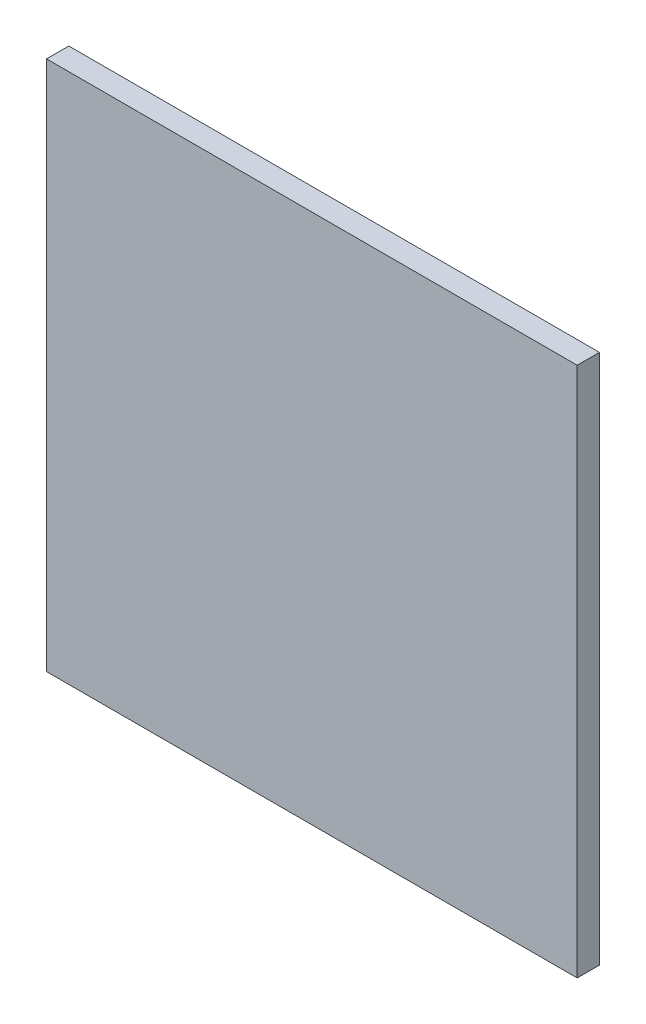
from build123d import *

# Parameters (mm, degrees)
SKETCH1_W           = 71.5
SKETCH1_H           = 71.5
BOSS_EXTRUDE1_DEPTH = 3


with BuildPart() as part:
    # Sketch1 → Boss-Extrude1 (new body)
    with BuildSketch(Plane.XY):
        with Locations((35.75, 35.75)):
            Rectangle(SKETCH1_W, SKETCH1_H)
    extrude(amount=BOSS_EXTRUDE1_DEPTH)


solid = part.part
